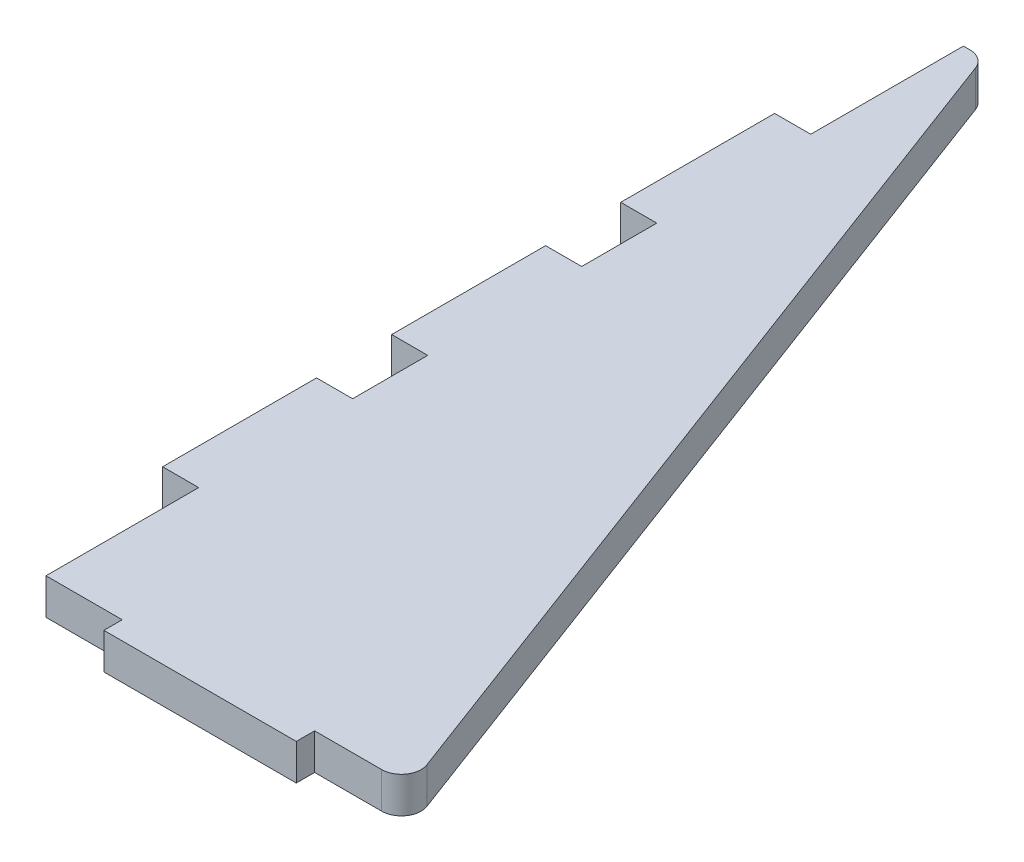
from build123d import *

# Parameters (mm, degrees)
BOSS_EXTRUDE1_DEPTH = 6
SKETCH2_W           = 6
SKETCH2_H           = 25.4
SKETCH2_W_2         = 31.8008
SKETCH2_H_2         = 3.048
BOSS_EXTRUDE4_DEPTH = 6
FILLET1_R           = 3.175
KERF_DEPTH          = 6


with BuildPart() as part:
    # Sketch1 → Boss-Extrude1 (new body)
    with BuildSketch(Plane(origin=(0, 0, 0), x_dir=(1, 0, 0), z_dir=(0, 1, 0))):
        Polygon((-3.175, 76.2), (-3.175, -76.2), (57.15, -76.2), (0, 76.2), align=None)
    extrude(amount=BOSS_EXTRUDE1_DEPTH)

    # Sketch2 → Boss-Extrude4 (add)
    with BuildSketch(Plane(origin=(0, 0, 0), x_dir=(1, 0, 0), z_dir=(0, 1, 0))):
        with Locations((-6.175, 0)):
            Rectangle(SKETCH2_W, SKETCH2_H)
        with Locations((-6.175, 38.1)):
            Rectangle(SKETCH2_W, SKETCH2_H)
        with Locations((-6.175, -38.1)):
            Rectangle(SKETCH2_W, SKETCH2_H)
        with Locations((25.4, -77.724)):
            Rectangle(SKETCH2_W_2, SKETCH2_H_2)
    extrude(amount=BOSS_EXTRUDE4_DEPTH)

    # Fillet1
    fillet1_edges = [part.edges().sort_by_distance(p)[0] for p in [
        (0, 3, -76.2),
        (57.15, 3, 76.2),
    ]]
    fillet(fillet1_edges, radius=FILLET1_R)

    # Sketch3 → KERF (add)
    with BuildSketch(Plane(origin=(0, 6, 0), x_dir=(1, 0, 0), z_dir=(0, 1, 0))):
        with BuildLine():
            Line((41.402, -76.3016), (52.568473514, -76.3016))
            ThreePointArc((52.568473514, -76.3016), (55.261594992, -74.891334445), (55.636449697, -71.874508931))
            Line((55.636449697, -71.874508931), (0.867699697, 74.175491069))
            ThreePointArc((0.867699697, 74.175491069), (-0.333942041, 75.718121478), (-2.200276486, 76.3016))
            Line((-2.200276486, 76.3016), (-3.2766, 76.3016))
            Line((-3.2766, 76.3016), (-3.2766, 50.9016))
            Line((-3.2766, 50.9016), (-9.2766, 50.9016))
            Line((-9.2766, 50.9016), (-9.2766, 25.2984))
            Line((-9.2766, 25.2984), (-3.2766, 25.2984))
            Line((-3.2766, 25.2984), (-3.2766, 12.8016))
            Line((-3.2766, 12.8016), (-9.2766, 12.8016))
            Line((-9.2766, 12.8016), (-9.2766, -12.8016))
            Line((-9.2766, -12.8016), (-3.2766, -12.8016))
            Line((-3.2766, -12.8016), (-3.2766, -25.2984))
            Line((-3.2766, -25.2984), (-9.2766, -25.2984))
            Line((-9.2766, -25.2984), (-9.2766, -50.9016))
            Line((-9.2766, -50.9016), (-3.2766, -50.9016))
            Line((-3.2766, -50.9016), (-3.2766, -76.3016))
            Line((-3.2766, -76.3016), (9.398, -76.3016))
            Line((9.398, -76.3016), (9.398, -79.3496))
            Line((9.398, -79.3496), (41.402, -79.3496))
            Line((41.402, -79.3496), (41.402, -76.3016))
        make_face()
    extrude(amount=-KERF_DEPTH)


solid = part.part
